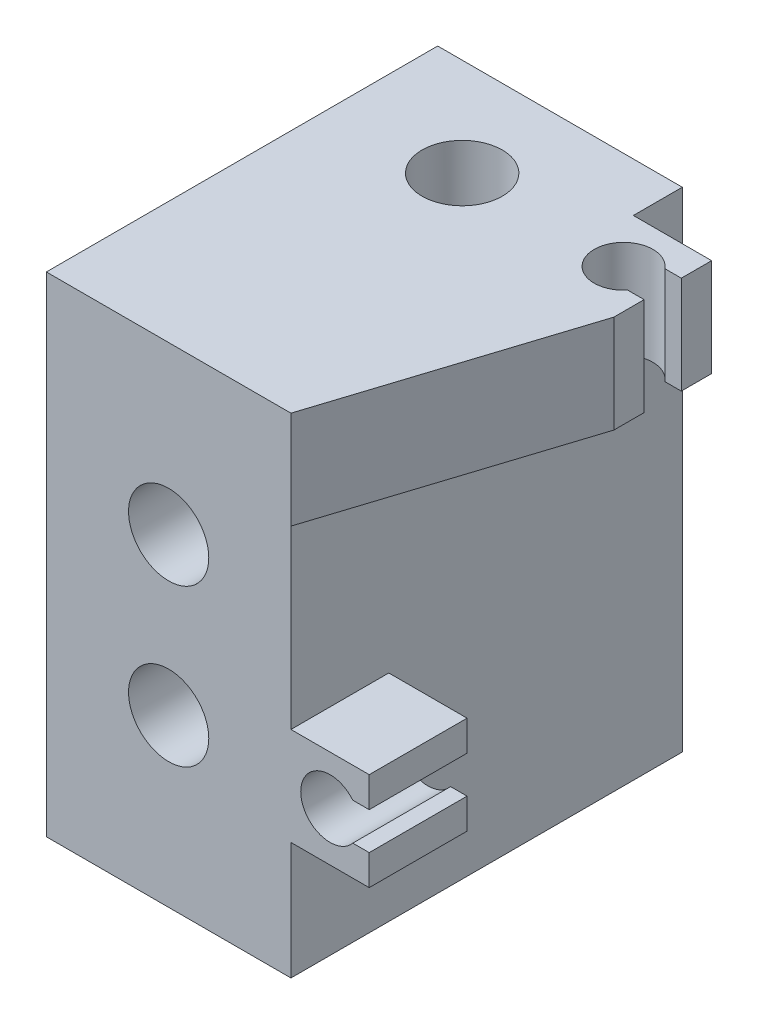
from build123d import *

# Parameters (mm, degrees)
SKETCH1_W           = 25
SKETCH1_H           = 40
BOSS_EXTRUDE1_DEPTH = 50
SKETCH2_R           = 4.1
CUT_EXTRUDE1_DEPTH  = 51
SKETCH3_R           = 4.1
CUT_EXTRUDE2_DEPTH  = 41
CUT_EXTRUDE3_DEPTH  = 21
BOSS_EXTRUDE2_DEPTH = 10
BOSS_EXTRUDE3_DEPTH = 10
CHAMFER1_SIZE       = 1
BOSS_EXTRUDE4_DEPTH = 10


with BuildPart() as part:
    # Sketch1 → Boss-Extrude1 (new body)
    with BuildSketch(Plane(origin=(0, 0, 0), x_dir=(1, 0, 0), z_dir=(0, 1, 0))):
        Rectangle(SKETCH1_W, SKETCH1_H)
    extrude(amount=BOSS_EXTRUDE1_DEPTH)

    # Sketch2 → Cut-Extrude1 (cut, through all)
    with BuildSketch(Plane.XZ):
        with Locations((0, -10)):
            Circle(SKETCH2_R)
    extrude(amount=-CUT_EXTRUDE1_DEPTH, mode=Mode.SUBTRACT)

    # Sketch3 → Cut-Extrude2 (cut, through all)
    with BuildSketch(Plane.XY.offset(20)):
        with Locations((0, 17)):
            Circle(SKETCH3_R)
        with Locations((0, 33)):
            Circle(SKETCH3_R)
    extrude(amount=-CUT_EXTRUDE2_DEPTH, mode=Mode.SUBTRACT)

    # Sketch4 → Cut-Extrude3 (cut)
    with BuildSketch(Plane(origin=(0, 0, -20), x_dir=(-1, 0, 0), z_dir=(0, 0, -1))):
        Polygon((-7.5, 17), (-3.75, 10.504809472), (3.75, 10.504809472), (7.5, 17), (3.75, 23.495190528), (-3.75, 23.495190528), align=None)
        Polygon((3.75, 39.495190528), (-3.75, 39.495190528), (-7.5, 33), (-3.75, 26.504809472), (3.75, 26.504809472), (7.5, 33), align=None)
    extrude(amount=-CUT_EXTRUDE3_DEPTH, mode=Mode.SUBTRACT)

    # Sketch5 → Boss-Extrude2 (add)
    with BuildSketch(Plane(origin=(0, 50, 0), x_dir=(1, 0, 0), z_dir=(0, 1, 0))):
        with BuildLine():
            Line((12.5, 5), (20.5, 5))
            Line((20.5, 5), (20.5, 8.1))
            Line((20.5, 8.1), (18.821637353, 8.1))
            ThreePointArc((18.821637353, 8.1), (13.5, 10), (18.821637353, 11.9))
            Line((18.821637353, 11.9), (20.5, 11.9))
            Line((20.5, 11.9), (20.5, 15))
            Line((20.5, 15), (12.5, 15))
            Line((12.5, 15), (12.5, 5))
        make_face()
    extrude(amount=-BOSS_EXTRUDE2_DEPTH)

    # Sketch6 → Boss-Extrude3 (add)
    with BuildSketch(Plane.XY.offset(20)):
        with BuildLine():
            Line((12.5, 12), (20.5, 12))
            Line((20.5, 12), (20.5, 15.1))
            Line((20.5, 15.1), (18.821637353, 15.1))
            ThreePointArc((18.821637353, 15.1), (13.5, 17), (18.821637353, 18.9))
            Line((18.821637353, 18.9), (20.5, 18.9))
            Line((20.5, 18.9), (20.5, 22))
            Line((20.5, 22), (12.5, 22))
            Line((12.5, 22), (12.5, 12))
        make_face()
    extrude(amount=-BOSS_EXTRUDE3_DEPTH)

    # Chamfer1
    chamfer1_edges = [part.edges().sort_by_distance(p)[0] for p in [
        (5.625, 20.247595264, -20),
        (5.625, 13.752404736, -20),
        (0, 10.504809472, -20),
        (-5.625, 13.752404736, -20),
        (-5.625, 20.247595264, -20),
        (0, 23.495190528, -20),
        (-5.625, 36.247595264, -20),
        (0, 39.495190528, -20),
        (5.625, 36.247595264, -20),
        (5.625, 29.752404736, -20),
        (0, 26.504809472, -20),
        (-5.625, 29.752404736, -20),
    ]]
    chamfer(chamfer1_edges, length=CHAMFER1_SIZE)

    # Sketch7 → Boss-Extrude4 (add)
    with BuildSketch(Plane(origin=(0, 50, 0), x_dir=(1, 0, 0), z_dir=(0, 1, 0))):
        Polygon((20.5, 5), (12.5, -20), (12.5, 5), align=None)
    extrude(amount=-BOSS_EXTRUDE4_DEPTH)


solid = part.part
